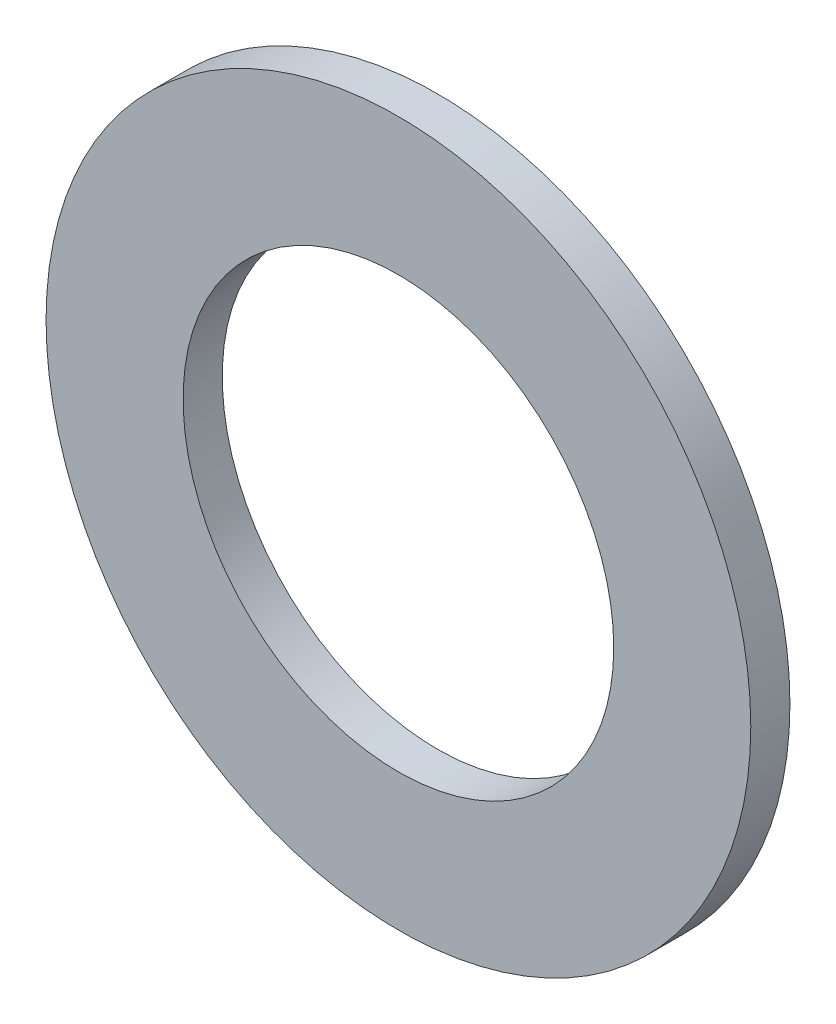
from build123d import *

# Parameters (mm, degrees)
SKETCH_1_R      = 36
SKETCH_1_R_2    = 22
EXTRUDE_1_DEPTH = 4


with BuildPart() as part:
    # Эскиз1 → Бобышка-Вытянуть1 (new body)
    with BuildSketch(Plane.XY):
        Circle(SKETCH_1_R)
        Circle(SKETCH_1_R_2, mode=Mode.SUBTRACT)
    extrude(amount=EXTRUDE_1_DEPTH)


solid = part.part
